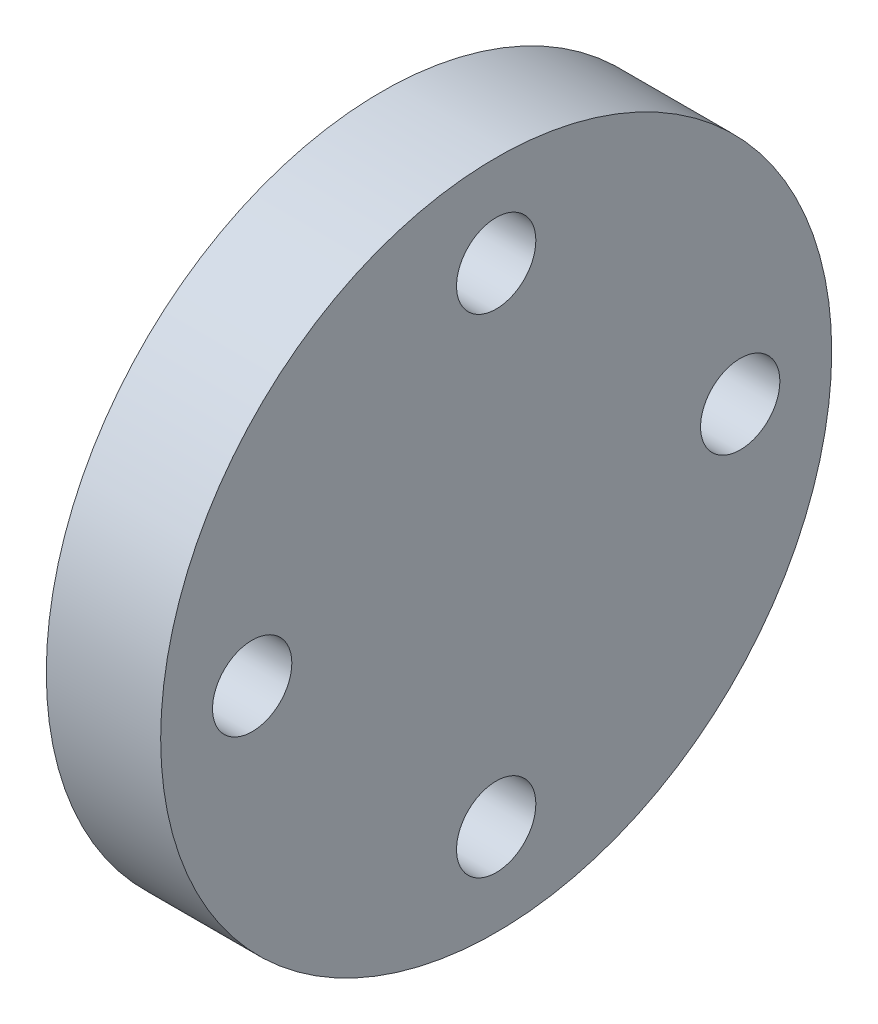
from build123d import *

# Parameters (mm, degrees)
SKETCH1_R           = 13.97
SKETCH1_R_2         = 1.651
BOSS_EXTRUDE1_DEPTH = 4.7625


with BuildPart() as part:
    # Sketch1 → Boss-Extrude1 (new body)
    with BuildSketch(Plane(origin=(0, 0, 0), x_dir=(0, 0, -1), z_dir=(1, 0, 0))):
        Circle(SKETCH1_R)
        with Locations((-10.16, 0)):
            Circle(SKETCH1_R_2, mode=Mode.SUBTRACT)
        with Locations((0, 10.16)):
            Circle(SKETCH1_R_2, mode=Mode.SUBTRACT)
        with Locations((10.16, 0)):
            Circle(SKETCH1_R_2, mode=Mode.SUBTRACT)
        with Locations((0, -10.16)):
            Circle(SKETCH1_R_2, mode=Mode.SUBTRACT)
    extrude(amount=BOSS_EXTRUDE1_DEPTH)


solid = part.part
